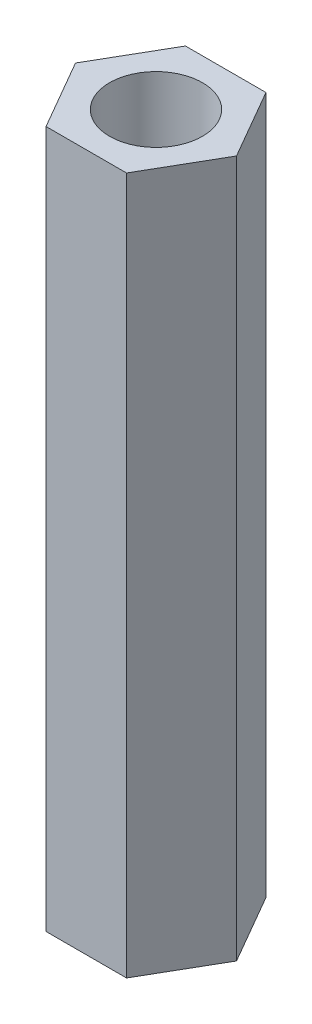
from build123d import *

# Parameters (mm, degrees)
SKETCH1_R           = 2
BOSS_EXTRUDE1_DEPTH = 30


with BuildPart() as part:
    # Sketch1 → Boss-Extrude1 (new body)
    with BuildSketch(Plane(origin=(0, 0, 0), x_dir=(1, 0, 0), z_dir=(0, 1, 0))):
        Polygon((3.464101615, 0), (1.732050808, 3), (-1.732050808, 3), (-3.464101615, 0), (-1.732050808, -3), (1.732050808, -3), align=None)
        Circle(SKETCH1_R, mode=Mode.SUBTRACT)
    extrude(amount=BOSS_EXTRUDE1_DEPTH)


solid = part.part
